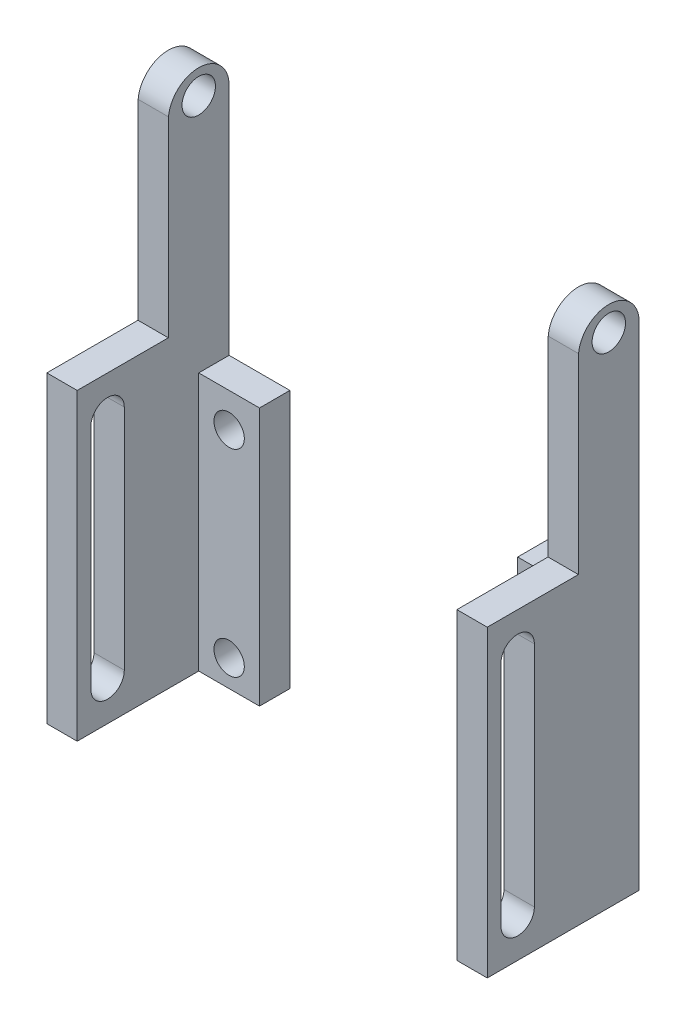
from build123d import *

# Parameters (mm, degrees)
SKETCH_1_W          = 2
SKETCH_1_H          = 35
EXTRUDE_1_DEPTH     = 4
EXTRUDE_1_2_DEPTH   = 4
SKETCH_2_W          = 4
SKETCH_2_H          = 17
EXTRUDE_2_DEPTH     = 2
SKETCH_3_R          = 1
CUT_EXTRUDE_1_DEPTH = 2
SKETCH_5_W          = 2
SKETCH_5_H          = 20
EXTRUDE_3_DEPTH     = 6
CUT_EXTRUDE_2_DEPTH = 29.99338081
CUT_EXTRUDE_3_DEPTH = 29.99338081
CUT_EXTRUDE_4_DEPTH = 29.99338081
SKETCH_9_R          = 1.1
CUT_EXTRUDE_5_DEPTH = 29.99338081


with BuildPart() as part:
    # 草图1 → 凸台-拉伸1 (new body)
    with BuildSketch(Plane.XY):
        with Locations((-37.996690405, -20.5)):
            Rectangle(SKETCH_1_W, SKETCH_1_H)
    extrude(amount=-EXTRUDE_1_DEPTH)



with BuildPart() as body_2:
    # 草图1 → Extrude 1 2 (new body)
    with BuildSketch(Plane.XY):
        with Locations((-11.003309595, -20.5)):
            Rectangle(SKETCH_1_W, SKETCH_1_H)
    extrude(amount=-EXTRUDE_1_2_DEPTH)


with BuildPart() as part_1:
    add(part.part)

    add(body_2.part)  # 凸台-拉伸2 merges body 2
    # 草图2 → 凸台-拉伸2 (add)
    with BuildSketch(Plane(origin=(0, 0, -4), x_dir=(-1, 0, 0), z_dir=(0, 0, -1))):
        with Locations((34.996690405, -29.5)):
            Rectangle(SKETCH_2_W, SKETCH_2_H)
        with Locations((14.003309595, -29.5)):
            Rectangle(SKETCH_2_W, SKETCH_2_H)
    extrude(amount=-EXTRUDE_2_DEPTH)

    # 草图3 → 切除-拉伸1 (cut)
    with BuildSketch(Plane(origin=(0, 0, -4), x_dir=(-1, 0, 0), z_dir=(0, 0, -1))):
        with Locations((34.996690405, -36.24616654)):
            Circle(SKETCH_3_R)
        with Locations((34.996690405, -23.24616654)):
            Circle(SKETCH_3_R)
        with Locations((14.003309595, -36.24616654)):
            Circle(SKETCH_3_R)
        with Locations((14.003309595, -23.24616654)):
            Circle(SKETCH_3_R)
    extrude(amount=-CUT_EXTRUDE_1_DEPTH, mode=Mode.SUBTRACT)

    # 草图5 → 凸台-拉伸3 (add)
    with BuildSketch(Plane.XY):
        with Locations((-11.003309595, -28)):
            Rectangle(SKETCH_5_W, SKETCH_5_H)
        with Locations((-37.996690405, -28)):
            Rectangle(SKETCH_5_W, SKETCH_5_H)
    extrude(amount=EXTRUDE_3_DEPTH)

    # 草图6 → 切除-拉伸2 (cut, through all)
    with BuildSketch(Plane(origin=(-10.003309595, 0, 0), x_dir=(0, 0, -1), z_dir=(1, 0, 0))):
        with BuildLine():
            Line((-5.1, -20.5), (-5.1, -35.5))
            ThreePointArc((-5.1, -35.5), (-4, -36.6), (-2.9, -35.5))
            Line((-2.9, -35.5), (-2.9, -20.5))
            ThreePointArc((-2.9, -20.5), (-4, -19.4), (-5.1, -20.5))
        make_face()
    extrude(amount=-CUT_EXTRUDE_2_DEPTH, mode=Mode.SUBTRACT)

    # 草图7 → 切除-拉伸3 (cut, through all)
    with BuildSketch(Plane(origin=(-10.003309595, 0, 0), x_dir=(0, 0, -1), z_dir=(1, 0, 0))):
        with BuildLine():
            Line((4, -3), (0, -3))
            Line((0, -3), (0, -5.4))
            ThreePointArc((0, -5.4), (2, -3.4), (4, -5.4))
            Line((4, -5.4), (4, -3))
        make_face()
    extrude(amount=-CUT_EXTRUDE_3_DEPTH, mode=Mode.SUBTRACT)

    # 草图8 → 切除-拉伸4 (cut, through all)
    with BuildSketch(Plane(origin=(-10.003309595, 0, 0), x_dir=(0, 0, -1), z_dir=(1, 0, 0))):
        with BuildLine():
            ThreePointArc((4, -5.4), (2, -3.4), (0, -5.4))
            ThreePointArc((0, -5.4), (0.000625489, -5.450015642), (0.002501564, -5.5))
            ThreePointArc((0.002501564, -5.5), (2, -3.6), (3.997498436, -5.5))
            ThreePointArc((3.997498436, -5.5), (3.999374511, -5.450015642), (4, -5.4))
        make_face()
    extrude(amount=-CUT_EXTRUDE_4_DEPTH, mode=Mode.SUBTRACT)

    # 草图9 → 切除-拉伸5 (cut, through all)
    with BuildSketch(Plane(origin=(-10.003309595, 0, 0), x_dir=(0, 0, -1), z_dir=(1, 0, 0))):
        with Locations((2, -5.2)):
            Circle(SKETCH_9_R)
    extrude(amount=-CUT_EXTRUDE_5_DEPTH, mode=Mode.SUBTRACT)


solid = part_1.part
